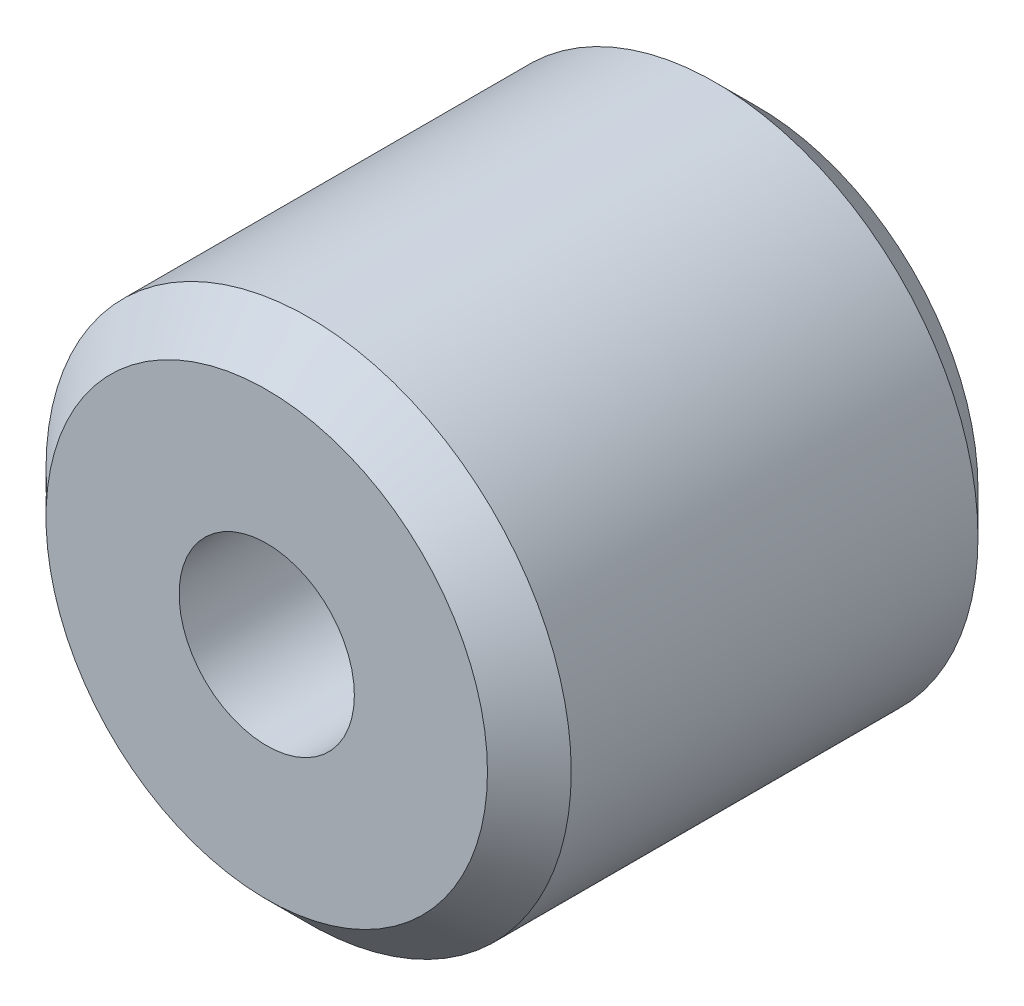
from build123d import *

# Parameters (mm, degrees)
SKETCH1_R           = 4.765
SKETCH1_R_2         = 1.59
BOSS_EXTRUDE1_DEPTH = 4.45
CHAMFER1_SIZE       = 0.76


with BuildPart() as part:
    # Sketch1 → Boss-Extrude1 (new body, symmetric)
    with BuildSketch(Plane.XY):
        Circle(SKETCH1_R)
        Circle(SKETCH1_R_2, mode=Mode.SUBTRACT)
    extrude(amount=BOSS_EXTRUDE1_DEPTH, both=True)

    # Chamfer1
    chamfer1_edges = [part.edges().sort_by_distance(p)[0] for p in [
        (-4.765, 0, -4.45),
        (-4.765, 0, 4.45),
    ]]
    chamfer(chamfer1_edges, length=CHAMFER1_SIZE)


solid = part.part
